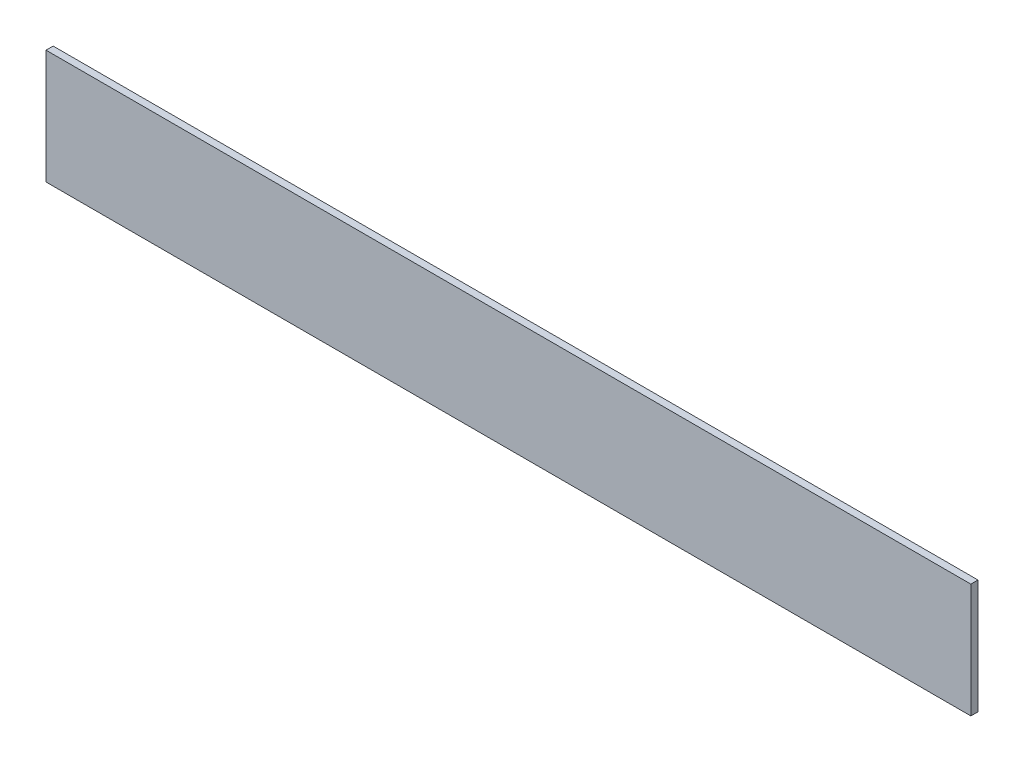
from build123d import *

# Parameters (mm, degrees)
SKETCH1_W           = 822.96
SKETCH1_H           = 101.6
BOSS_EXTRUDE1_DEPTH = 6.35


with BuildPart() as part:
    # Sketch1 → Boss-Extrude1 (new body)
    with BuildSketch(Plane.XY):
        with Locations((411.48, 50.8)):
            Rectangle(SKETCH1_W, SKETCH1_H)
    extrude(amount=BOSS_EXTRUDE1_DEPTH)


solid = part.part
